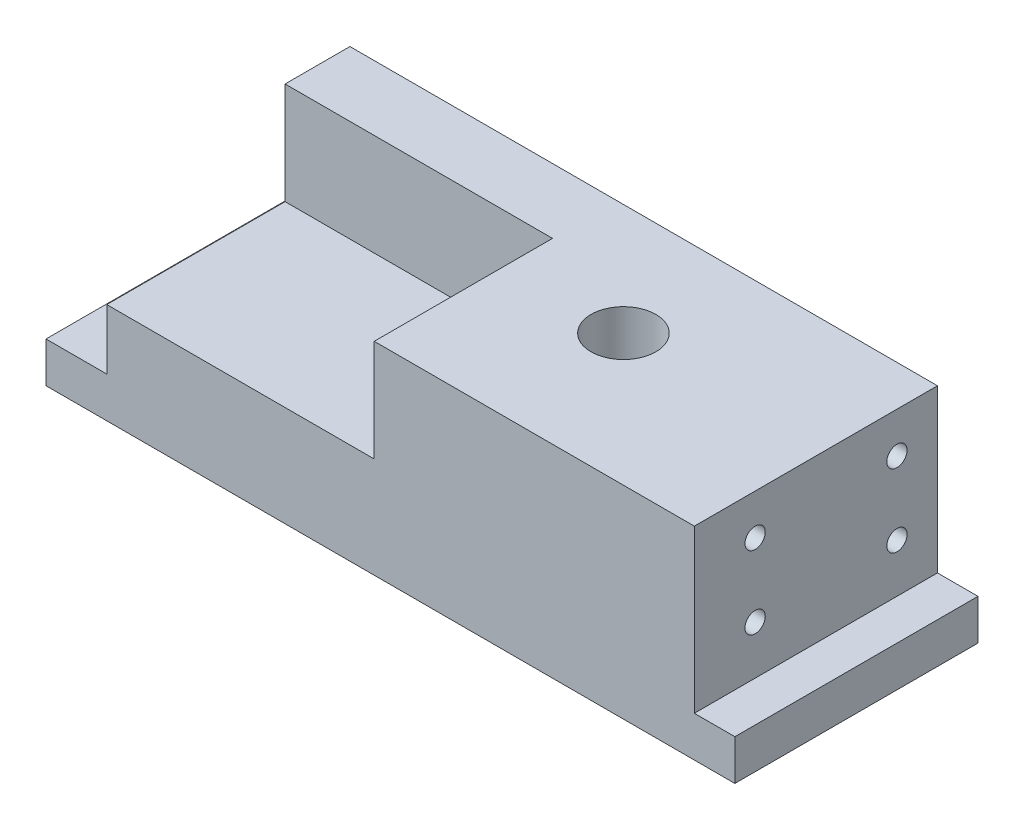
from build123d import *

# Parameters (mm, degrees)
AUFSATZ_LINEAR_AUSTRAGEN1_DEPTH = 65
SKIZZE3_R                       = 8
SCHNITT_LINEAR_AUSTRAGEN2_DEPTH = 85
SKIZZE4_W                       = 66
SKIZZE4_H                       = 25.15
SCHNITT_LINEAR_AUSTRAGEN3_DEPTH = 120
SKIZZE5_R                       = 2.5
SCHNITT_LINEAR_AUSTRAGEN4_DEPTH = 15
SKIZZE6_R                       = 2.5
SCHNITT_LINEAR_AUSTRAGEN5_DEPTH = 12
SKIZZE7_W                       = 21
SKIZZE7_H                       = 25.15
AUFSATZ_LINEAR_AUSTRAGEN2_DEPTH = 66
SKIZZE8_R                       = 2.5
SCHNITT_LINEAR_AUSTRAGEN7_DEPTH = 12
SCHNITT_LINEAR_AUSTRAGEN8_DEPTH = 5
SKIZZE10_W                      = 60
SKIZZE10_H                      = 10
AUFSATZ_LINEAR_AUSTRAGEN3_DEPTH = 2


with BuildPart() as part:
    # Skizze1 → Aufsatz-Linear austragen1 (new body)
    with BuildSketch(Plane.XY):
        Polygon((0, 0), (168, 0), (168, 10), (158, 10), (158, 50), (13, 50), (13, 10), (0, 10), align=None)
    extrude(amount=AUFSATZ_LINEAR_AUSTRAGEN1_DEPTH)

    # Skizze3 → Schnitt-Linear austragen2 (cut)
    with BuildSketch(Plane(origin=(0, 0, 0), x_dir=(-1, 0, 0), z_dir=(0, -1, 0))):
        with Locations((-108, -32.5)):
            Circle(SKIZZE3_R)
    extrude(amount=-SCHNITT_LINEAR_AUSTRAGEN2_DEPTH, mode=Mode.SUBTRACT)

    # Skizze4 → Schnitt-Linear austragen3 (cut)
    with BuildSketch(Plane(origin=(0, 0, 0), x_dir=(-1, 0, 0), z_dir=(0, 0, -1))):
        with Locations((-46, 37.425)):
            Rectangle(SKIZZE4_W, SKIZZE4_H)
    extrude(amount=-SCHNITT_LINEAR_AUSTRAGEN3_DEPTH, mode=Mode.SUBTRACT)

    # Skizze5 → Schnitt-Linear austragen4 (cut)
    with BuildSketch(Plane(origin=(158, 0, 0), x_dir=(0, 0, -1), z_dir=(1, 0, 0))):
        with Locations((-50, 40)):
            Circle(SKIZZE5_R)
        with Locations((-50, 22)):
            Circle(SKIZZE5_R)
        with Locations((-15, 22)):
            Circle(SKIZZE5_R)
        with Locations((-15, 40)):
            Circle(SKIZZE5_R)
    extrude(amount=-SCHNITT_LINEAR_AUSTRAGEN4_DEPTH, mode=Mode.SUBTRACT)

    # Skizze6 → Schnitt-Linear austragen5 (cut)
    with BuildSketch(Plane.ZY.offset(-13)):
        with Locations((15, 18)):
            Circle(SKIZZE6_R)
        with Locations((50, 18)):
            Circle(SKIZZE6_R)
    extrude(amount=-SCHNITT_LINEAR_AUSTRAGEN5_DEPTH, mode=Mode.SUBTRACT)

    # Skizze7 → Aufsatz-Linear austragen2 (add)
    with BuildSketch(Plane.ZY.offset(-13)):
        with Locations((10.5, 37.425)):
            Rectangle(SKIZZE7_W, SKIZZE7_H)
    extrude(amount=-AUFSATZ_LINEAR_AUSTRAGEN2_DEPTH)

    # Skizze8 → Schnitt-Linear austragen7 (cut)
    with BuildSketch(Plane.ZY.offset(-13)):
        with Locations((15, 40)):
            Circle(SKIZZE8_R)
    extrude(amount=-SCHNITT_LINEAR_AUSTRAGEN7_DEPTH, mode=Mode.SUBTRACT)

    # Skizze9 → Schnitt-Linear austragen8 (cut)
    with BuildSketch(Plane(origin=(0, 0, 0), x_dir=(-1, 0, 0), z_dir=(0, 0, -1))):
        Polygon((0, 0), (0, 10), (-13, 10), (-13, 50), (-158, 50), (-158, 10), (-168, 10), (-168, 0), align=None)
    extrude(amount=-SCHNITT_LINEAR_AUSTRAGEN8_DEPTH, mode=Mode.SUBTRACT)

    # Skizze10 → Aufsatz-Linear austragen3 (add)
    with BuildSketch(Plane.ZY):
        with Locations((35, 5)):
            Rectangle(SKIZZE10_W, SKIZZE10_H)
    extrude(amount=AUFSATZ_LINEAR_AUSTRAGEN3_DEPTH)


solid = part.part
